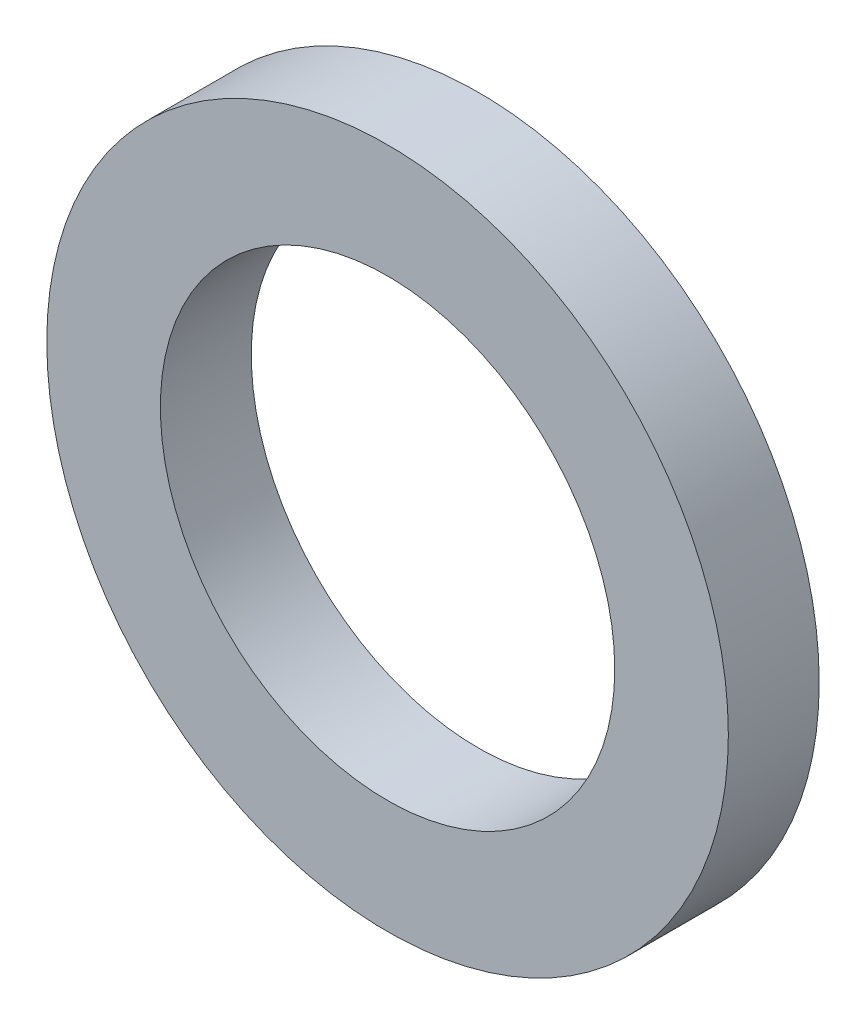
from build123d import *

# Parameters (mm, degrees)
CROQUIS1_R              = 3
CROQUIS1_R_2            = 2
SALIENTE_EXTRUIR1_DEPTH = 0.8


with BuildPart() as part:
    # Croquis1 → Saliente-Extruir1 (new body)
    with BuildSketch(Plane.XY):
        Circle(CROQUIS1_R)
        Circle(CROQUIS1_R_2, mode=Mode.SUBTRACT)
    extrude(amount=SALIENTE_EXTRUIR1_DEPTH)


solid = part.part
